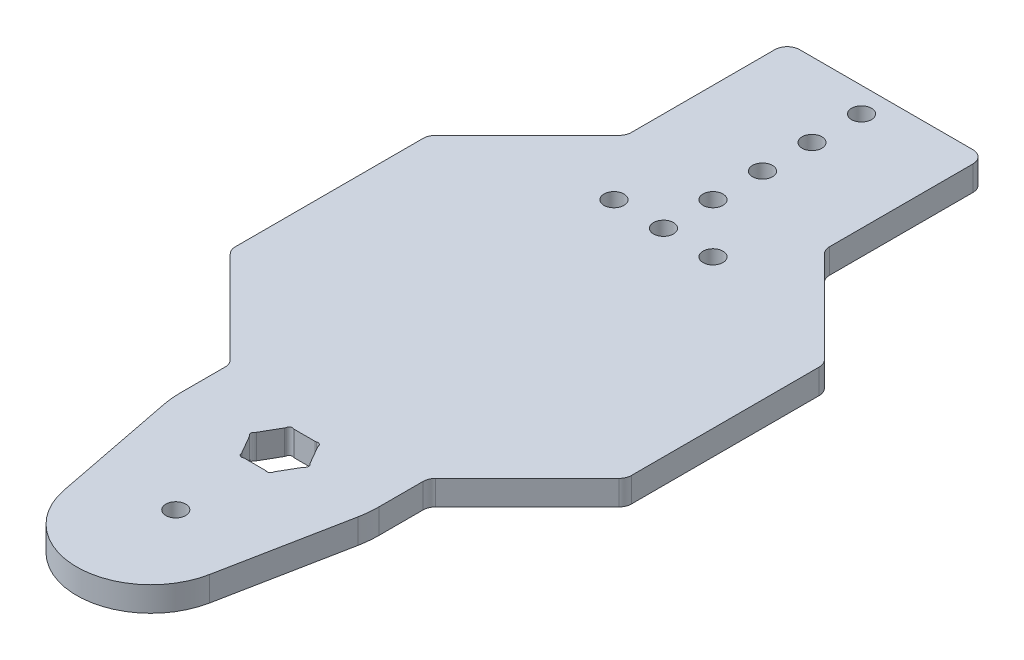
from build123d import *

# Parameters (mm, degrees)
SKETCH1_R           = 2.5527
BOSS_EXTRUDE1_DEPTH = 6.35


with BuildPart() as part:
    # Sketch1 → Boss-Extrude1 (new body)
    with BuildSketch(Plane(origin=(0, 0, 0), x_dir=(1, 0, 0), z_dir=(0, 1, 0))):
        with BuildLine():
            Line((-26.32993597, 49.87006403), (-49.87006403, 26.32993597))
            ThreePointArc((-49.87006403, 26.32993597), (-50.558317516, 25.299891837), (-50.8, 24.084871939))
            Line((-50.8, 24.084871939), (-50.8, -24.084871939))
            ThreePointArc((-50.8, -24.084871939), (-50.558317516, -25.299891837), (-49.87006403, -26.32993597))
            Line((-49.87006403, -26.32993597), (-26.32993597, -49.87006403))
            ThreePointArc((-26.32993597, -49.87006403), (-25.641682484, -50.900108163), (-25.4, -52.115128061))
            Line((-25.4, -52.115128061), (-25.4, -63.5))
            ThreePointArc((-25.4, -63.5), (-25.281197373, -65.953784703), (-24.925900837, -68.384615385))
            Line((-24.925900837, -68.384615385), (-18.694425628, -100.183461538))
            ThreePointArc((-18.694425628, -100.183461538), (0, -115.57), (18.694425628, -100.183461538))
            Line((18.694425628, -100.183461538), (24.925900837, -68.384615385))
            ThreePointArc((24.925900837, -68.384615385), (25.281197373, -65.953784703), (25.4, -63.5))
            Line((25.4, -63.5), (25.4, -52.115128061))
            ThreePointArc((25.4, -52.115128061), (25.641682484, -50.900108163), (26.32993597, -49.87006403))
            Line((26.32993597, -49.87006403), (49.87006403, -26.32993597))
            ThreePointArc((49.87006403, -26.32993597), (50.558317516, -25.299891837), (50.8, -24.084871939))
            Line((50.8, -24.084871939), (50.8, 24.084871939))
            ThreePointArc((50.8, 24.084871939), (50.558317516, 25.299891837), (49.87006403, 26.32993597))
            Line((49.87006403, 26.32993597), (26.32993597, 49.87006403))
            ThreePointArc((26.32993597, 49.87006403), (25.641682484, 50.900108163), (25.4, 52.115128061))
            Line((25.4, 52.115128061), (25.4, 88.9))
            ThreePointArc((25.4, 88.9), (24.47006403, 91.14506403), (22.225, 92.075))
            Line((22.225, 92.075), (-22.225, 92.075))
            ThreePointArc((-22.225, 92.075), (-24.47006403, 91.14506403), (-25.4, 88.9))
            Line((-25.4, 88.9), (-25.4, 52.115128061))
            ThreePointArc((-25.4, 52.115128061), (-25.641682484, 50.900108163), (-26.32993597, 49.87006403))
        make_face()
        with Locations((0, -90.17)):
            Circle(SKETCH1_R, mode=Mode.SUBTRACT)
        with Locations((0, 85.725)):
            Circle(SKETCH1_R, mode=Mode.SUBTRACT)
        with Locations((0, 73.025)):
            Circle(SKETCH1_R, mode=Mode.SUBTRACT)
        with Locations((0, 60.325)):
            Circle(SKETCH1_R, mode=Mode.SUBTRACT)
        with Locations((0, 47.625)):
            Circle(SKETCH1_R, mode=Mode.SUBTRACT)
        with Locations((0, 34.925)):
            Circle(SKETCH1_R, mode=Mode.SUBTRACT)
        with Locations((-12.7, 34.925)):
            Circle(SKETCH1_R, mode=Mode.SUBTRACT)
        with Locations((12.7, 34.925)):
            Circle(SKETCH1_R, mode=Mode.SUBTRACT)
        with BuildLine():
            Line((-4.235994669, -68.990042012), (-6.872513185, -64.423457988))
            ThreePointArc((-6.872513185, -64.423457988), (-6.959446788, -64.301228024), (-7.06782229, -64.197534409))
            ThreePointArc((-7.06782229, -64.197534409), (-7.405671903, -63.5), (-7.06782229, -62.802465591))
            ThreePointArc((-7.06782229, -62.802465591), (-6.959446788, -62.698771976), (-6.872513185, -62.576542012))
            Line((-6.872513185, -62.576542012), (-4.235994669, -58.009957988))
            ThreePointArc((-4.235994669, -58.009957988), (-4.173607217, -57.873556297), (-4.137993663, -57.727853552))
            ThreePointArc((-4.137993663, -57.727853552), (-3.702835951, -57.0865), (-2.929828627, -57.030319143))
            ThreePointArc((-2.929828627, -57.030319143), (-2.785839571, -57.072328274), (-2.636518516, -57.0865))
            Line((-2.636518516, -57.0865), (2.636518516, -57.0865))
            ThreePointArc((2.636518516, -57.0865), (2.785839571, -57.072328274), (2.929828627, -57.030319143))
            ThreePointArc((2.929828627, -57.030319143), (3.702835951, -57.0865), (4.137993663, -57.727853552))
            ThreePointArc((4.137993663, -57.727853552), (4.173607217, -57.873556297), (4.235994669, -58.009957988))
            Line((4.235994669, -58.009957988), (6.872513185, -62.576542012))
            ThreePointArc((6.872513185, -62.576542012), (6.959446788, -62.698771976), (7.06782229, -62.802465591))
            ThreePointArc((7.06782229, -62.802465591), (7.405671903, -63.5), (7.06782229, -64.197534409))
            ThreePointArc((7.06782229, -64.197534409), (6.959446788, -64.301228024), (6.872513185, -64.423457988))
            Line((6.872513185, -64.423457988), (4.235994669, -68.990042012))
            ThreePointArc((4.235994669, -68.990042012), (4.173607217, -69.126443703), (4.137993663, -69.272146448))
            ThreePointArc((4.137993663, -69.272146448), (3.702835951, -69.9135), (2.929828627, -69.969680857))
            ThreePointArc((2.929828627, -69.969680857), (2.785839571, -69.927671726), (2.636518516, -69.9135))
            Line((2.636518516, -69.9135), (-2.636518516, -69.9135))
            ThreePointArc((-2.636518516, -69.9135), (-2.785839571, -69.927671726), (-2.929828627, -69.969680857))
            ThreePointArc((-2.929828627, -69.969680857), (-3.702835951, -69.9135), (-4.137993663, -69.272146448))
            ThreePointArc((-4.137993663, -69.272146448), (-4.173607217, -69.126443703), (-4.235994669, -68.990042012))
        make_face(mode=Mode.SUBTRACT)
    extrude(amount=-BOSS_EXTRUDE1_DEPTH)


solid = part.part
